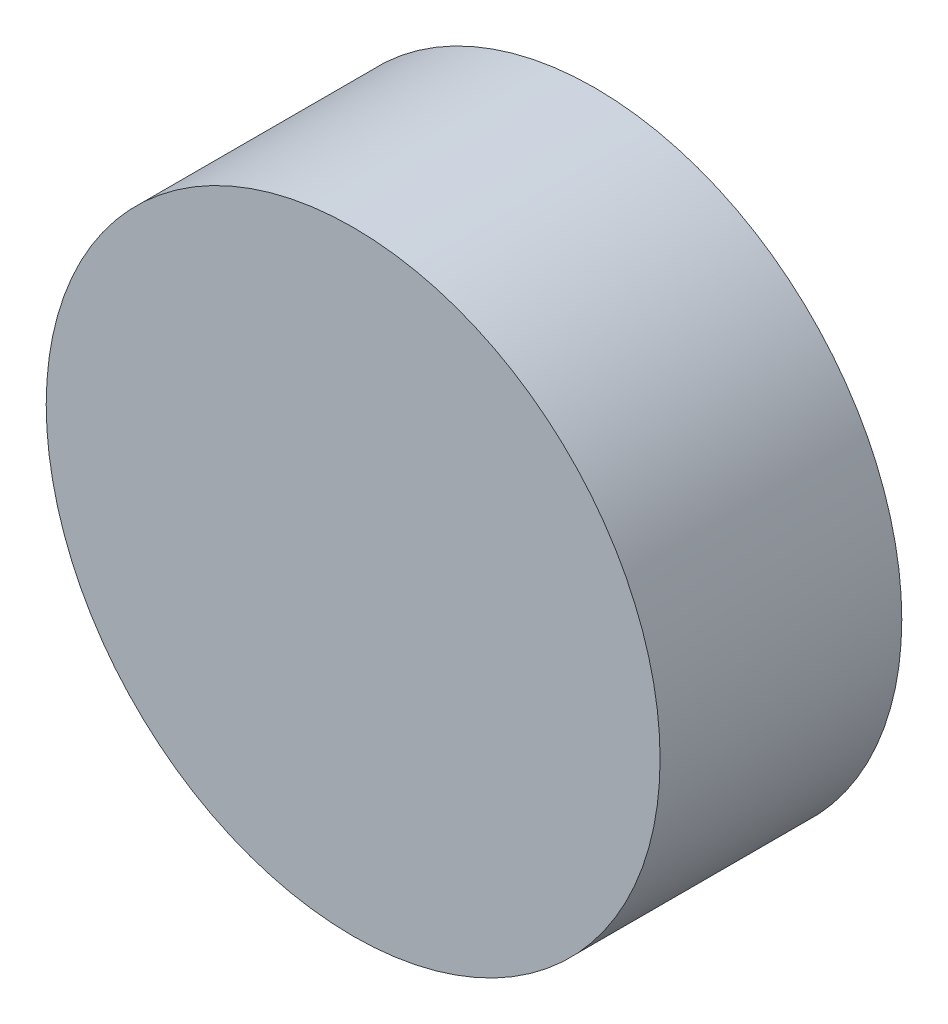
from build123d import *

# Parameters (mm, degrees)
CROQUIS1_R              = 101.6
SALIENTE_EXTRUIR1_DEPTH = 40


with BuildPart() as part:
    # Croquis1 → Saliente-Extruir1 (new body, symmetric)
    with BuildSketch(Plane.XY):
        Circle(CROQUIS1_R)
    extrude(amount=SALIENTE_EXTRUIR1_DEPTH, both=True)


solid = part.part
